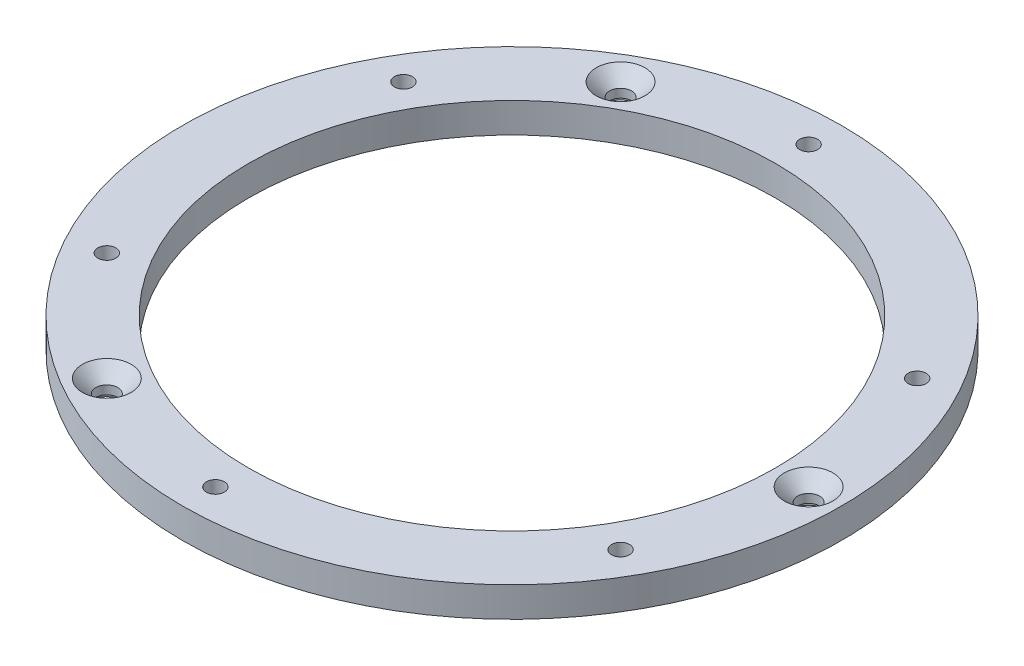
from build123d import *

# Parameters (mm, degrees)
SKETCH1_R                                            = 165
SKETCH1_R_2                                          = 132
BOSS_EXTRUDE1_DEPTH                                  = 15
M8_CLEARANCE_HOLE1_D                                 = 9
CIRPATTERN1_COUNT                                    = 6
SKETCH4_R                                            = 10
CUT_EXTRUDE1_DEPTH                                   = 4
CSK_FOR_M10_HEX_SOCKET_COUNTERSUNK_CAP_S_D           = 11
CSK_FOR_M10_HEX_SOCKET_COUNTERSUNK_CAP_S_CSINK_D     = 24.4
CSK_FOR_M10_HEX_SOCKET_COUNTERSUNK_CAP_S_CSINK_ANGLE = 90
CIRPATTERN2_COUNT                                    = 3


with BuildPart() as part:
    # Sketch1 → Boss-Extrude1 (new body)
    with BuildSketch(Plane(origin=(0, 0, 0), x_dir=(1, 0, 0), z_dir=(0, 1, 0))):
        Circle(SKETCH1_R)
        Circle(SKETCH1_R_2, mode=Mode.SUBTRACT)
    extrude(amount=BOSS_EXTRUDE1_DEPTH)

    # M8 Clearance Hole1 (through all)
    with Locations(Plane(origin=(0, 0, 0), x_dir=(-1, 0, 0), z_dir=(0, -1, 0))):
        with Locations((0, 148.5)):
            m8_clearance_hole1 = Hole(M8_CLEARANCE_HOLE1_D / 2)

    # CirPattern1: M8 Clearance Hole1 ×6 about axis
    cirpattern1_axis = Axis((0, 0, 0), (0, 1, 0))
    for i in range(1, CIRPATTERN1_COUNT):
        add(m8_clearance_hole1.rotate(cirpattern1_axis, i * 360 / CIRPATTERN1_COUNT), mode=Mode.SUBTRACT)

    # Sketch4 → Cut-Extrude1 (cut)
    with BuildSketch(Plane.XZ):
        with Locations((-74.25, 128.604772462)):
            Circle(SKETCH4_R)
    cut_extrude1 = extrude(amount=-CUT_EXTRUDE1_DEPTH, mode=Mode.SUBTRACT)

    # CSK for M10 Hex Socket Countersunk Cap Screw1 (through all)
    with Locations(Plane(origin=(0, 15, 0), x_dir=(1, 0, 0), z_dir=(0, 1, 0))):
        with Locations((-74.25, -128.604772462)):
            csk_for_m10_hex_socket_countersunk_cap_s = CounterSinkHole(CSK_FOR_M10_HEX_SOCKET_COUNTERSUNK_CAP_S_D / 2, CSK_FOR_M10_HEX_SOCKET_COUNTERSUNK_CAP_S_CSINK_D / 2, counter_sink_angle=CSK_FOR_M10_HEX_SOCKET_COUNTERSUNK_CAP_S_CSINK_ANGLE)

    # CirPattern2: Cut-Extrude1, CSK for M10 Hex Socket Countersunk Cap Screw1 ×3 about axis
    cirpattern2_axis = Axis((0, 0, 0), (0, 1, 0))
    for i in range(1, CIRPATTERN2_COUNT):
        add(cut_extrude1.rotate(cirpattern2_axis, i * 360 / CIRPATTERN2_COUNT), mode=Mode.SUBTRACT)
        add(csk_for_m10_hex_socket_countersunk_cap_s.rotate(cirpattern2_axis, i * 360 / CIRPATTERN2_COUNT), mode=Mode.SUBTRACT)


solid = part.part
